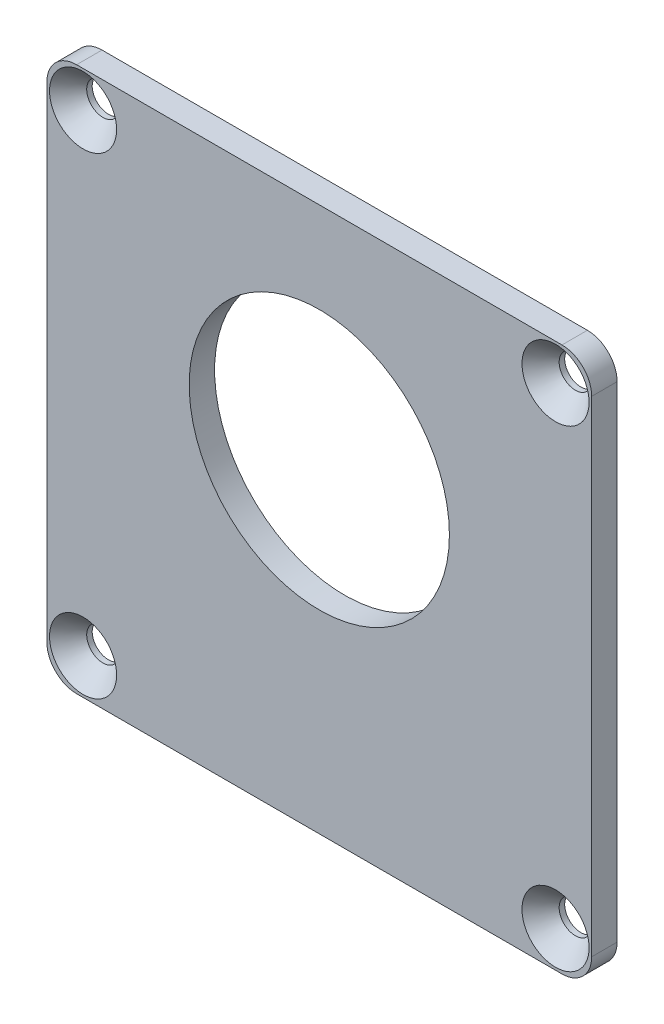
from build123d import *

# Parameters (mm, degrees)
BOSS_EXTRUDE1_DEPTH                           = 1.25
CSK_FOR_4_FLAT_HEAD_MACHINE_SCREW1_AT_2_COUNT = 2
CSK_FOR_4_FLAT_HEAD_MACHINE_SCREW1_AT_2_PITCH = 65.735474806
CSK_FOR_4_FLAT_HEAD_MACHINE_SCREW1_AT_3_COUNT = 2
CSK_FOR_4_FLAT_HEAD_MACHINE_SCREW1_AT_3_PITCH = 46.482
CSK_FOR_4_FLAT_HEAD_MACHINE_SCREW1_AT_4_COUNT = 2
CSK_FOR_4_FLAT_HEAD_MACHINE_SCREW1_AT_4_PITCH = 46.482
SKETCH7_R                                     = 12.8016
CUT_EXTRUDE1_DEPTH                            = 3.5


with BuildPart() as part:
    # Sketch1 → Boss-Extrude1 (new body, symmetric)
    with BuildSketch(Plane.XY):
        with BuildLine():
            Line((-23.876, 26.797), (23.876, 26.797))
            ThreePointArc((23.876, 26.797), (25.941458908, 25.941458908), (26.797, 23.876))
            Line((26.797, 23.876), (26.797, -23.876))
            ThreePointArc((26.797, -23.876), (25.941458908, -25.941458908), (23.876, -26.797))
            Line((23.876, -26.797), (-23.876, -26.797))
            ThreePointArc((-23.876, -26.797), (-25.941458908, -25.941458908), (-26.797, -23.876))
            Line((-26.797, -23.876), (-26.797, 23.876))
            ThreePointArc((-26.797, 23.876), (-25.941458908, 25.941458908), (-23.876, 26.797))
        make_face()
    extrude(amount=BOSS_EXTRUDE1_DEPTH, both=True)

    # Sketch5 → CSK for #4 Flat Head Machine Screw1 (revolve, cut)
    with BuildSketch(Plane(origin=(-23.241, 23.241, 1.25), x_dir=(0, -1, 0), z_dir=(1, 0, 0))):
        Polygon((0, 0), (0, 2.5), (1.6002, 2.5), (1.6002, 1.957696955), (3.302, 0), align=None)
    csk_for_4_flat_head_machine_screw1 = revolve(axis=Axis((-23.241, 23.241, 7.6), (0, 0, -1)), mode=Mode.SUBTRACT)

    # CSK for #4 Flat Head Machine Screw1 at 2: CSK for #4 Flat Head Machine Screw1 ×2
    with Locations(*[Vector(0.707106781, -0.707106781, 0) * (i * CSK_FOR_4_FLAT_HEAD_MACHINE_SCREW1_AT_2_PITCH) for i in range(1, CSK_FOR_4_FLAT_HEAD_MACHINE_SCREW1_AT_2_COUNT)]):
        add(csk_for_4_flat_head_machine_screw1, mode=Mode.SUBTRACT)

    # CSK for #4 Flat Head Machine Screw1 at 3: CSK for #4 Flat Head Machine Screw1 ×2
    with Locations(*[(i * CSK_FOR_4_FLAT_HEAD_MACHINE_SCREW1_AT_3_PITCH, 0, 0) for i in range(1, CSK_FOR_4_FLAT_HEAD_MACHINE_SCREW1_AT_3_COUNT)]):
        add(csk_for_4_flat_head_machine_screw1, mode=Mode.SUBTRACT)

    # CSK for #4 Flat Head Machine Screw1 at 4: CSK for #4 Flat Head Machine Screw1 ×2
    with Locations(*[(0, -i * CSK_FOR_4_FLAT_HEAD_MACHINE_SCREW1_AT_4_PITCH, 0) for i in range(1, CSK_FOR_4_FLAT_HEAD_MACHINE_SCREW1_AT_4_COUNT)]):
        add(csk_for_4_flat_head_machine_screw1, mode=Mode.SUBTRACT)

    # Sketch7 → Cut-Extrude1 (cut, through all)
    with BuildSketch(Plane.XY.offset(1.25)):
        with Locations((0, 5.08)):
            Circle(SKETCH7_R)
    extrude(amount=-CUT_EXTRUDE1_DEPTH, mode=Mode.SUBTRACT)


solid = part.part
